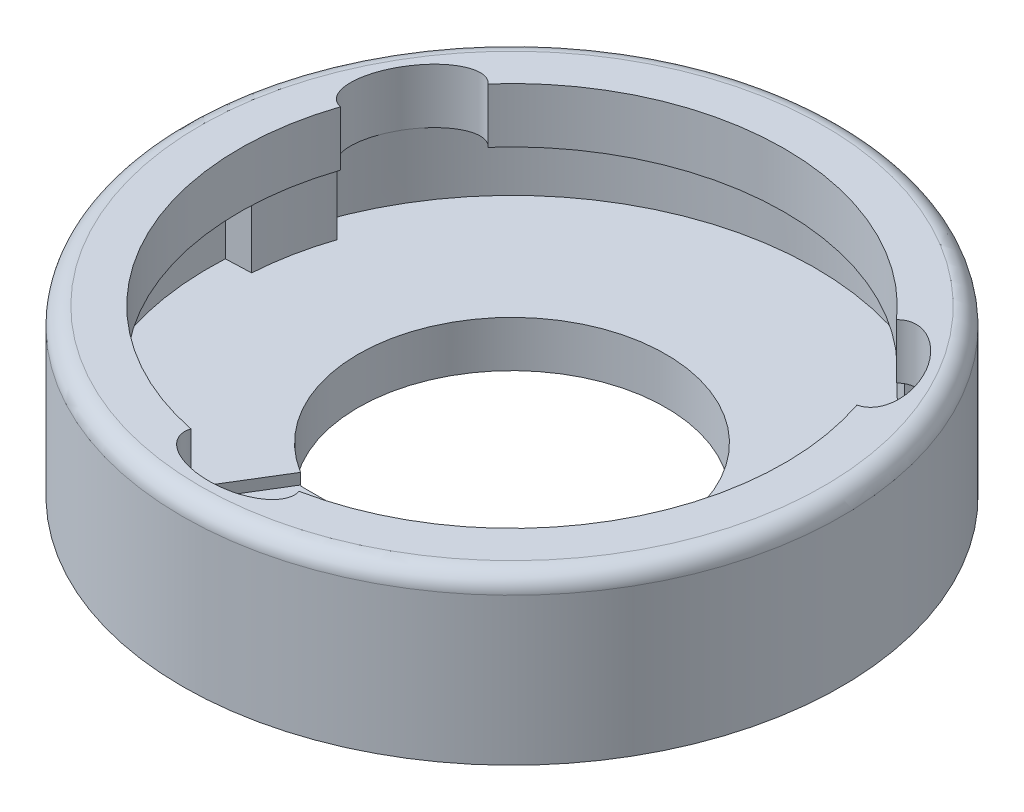
from build123d import *

# Parameters (mm, degrees)
SKIZZE1_R                       = 7.5
SKIZZE1_R_2                     = 3.5
AUFSATZ_LINEAR_AUSTRAGEN2_DEPTH = 0.8
SKIZZE5_R                       = 7.5
SKIZZE5_R_2                     = 6.9
AUFSATZ_LINEAR_AUSTRAGEN4_DEPTH = 1.7
SKIZZE18_R                      = 7.5
SKIZZE18_R_2                    = 6.2
AUFSATZ_LINEAR_AUSTRAGEN5_DEPTH = 1.25
SKIZZE19_RX                     = 1.25
SKIZZE19_RY                     = 0.7
SCHNITT_LINEAR_AUSTRAGEN1_DEPTH = 1.75
AUFSATZ_LINEAR_AUSTRAGEN6_DEPTH = 1.7
AUFSATZ_LINEAR_AUSTRAGEN7_DEPTH = 0.25
KREISMUSTER2_COUNT              = 3
KREISMUSTER4_COUNT              = 3
VERRUNDUNG1_R                   = 0.4
SKIZZE25_W                      = 3.608230109
SKIZZE25_H                      = 2.129095576
AUFSATZ_LINEAR_AUSTRAGEN8_DEPTH = 0.8


with BuildPart() as part:
    # Skizze1 → Aufsatz-Linear austragen2 (new body)
    with BuildSketch(Plane(origin=(0, 0, 0), x_dir=(1, 0, 0), z_dir=(0, 1, 0))):
        Circle(SKIZZE1_R)
        Circle(SKIZZE1_R_2, mode=Mode.SUBTRACT)
    extrude(amount=AUFSATZ_LINEAR_AUSTRAGEN2_DEPTH)

    # Skizze5 → Aufsatz-Linear austragen4 (add)
    with BuildSketch(Plane(origin=(0, 0.8, 0), x_dir=(1, 0, 0), z_dir=(0, 1, 0))):
        Circle(SKIZZE5_R)
        Circle(SKIZZE5_R_2, mode=Mode.SUBTRACT)
    extrude(amount=AUFSATZ_LINEAR_AUSTRAGEN4_DEPTH)

    # Skizze18 → Aufsatz-Linear austragen5 (add)
    with BuildSketch(Plane(origin=(0, 2.5, 0), x_dir=(1, 0, 0), z_dir=(0, 1, 0))):
        Circle(SKIZZE18_R)
        Circle(SKIZZE18_R_2, mode=Mode.SUBTRACT)
    extrude(amount=AUFSATZ_LINEAR_AUSTRAGEN5_DEPTH)

    # Skizze19 → Schnitt-Linear austragen1 (cut)
    with BuildSketch(Plane(origin=(0, 3.75, 0), x_dir=(1, 0, 0), z_dir=(0, 1, 0))):
        with Locations(Location((0, -6.2), (0, 0, 180))):
            Ellipse(SKIZZE19_RX, SKIZZE19_RY)
    schnitt_linear_austragen1 = extrude(amount=-SCHNITT_LINEAR_AUSTRAGEN1_DEPTH, mode=Mode.SUBTRACT)

    # Skizze21 → Aufsatz-Linear austragen6 (add)
    with BuildSketch(Plane(origin=(0, 0.8, 0), x_dir=(1, 0, 0), z_dir=(0, 1, 0))):
        with BuildLine():
            Line((1.25, -6.2), (1.58338324, -7.330954748))
            ThreePointArc((1.58338324, -7.330954748), (2.538105919, -7.057479603), (3.448325605, -6.660259043))
            Line((3.448325605, -6.660259043), (2.820309034, -5.661126827))
            ThreePointArc((2.820309034, -5.661126827), (2.052912561, -5.982311428), (1.25, -6.2))
        make_face()
    aufsatz_linear_austragen6 = extrude(amount=AUFSATZ_LINEAR_AUSTRAGEN6_DEPTH)

    # Skizze22 → Aufsatz-Linear austragen7 (add)
    with BuildSketch(Plane(origin=(0, 0.8, 0), x_dir=(1, 0, 0), z_dir=(0, 1, 0))):
        with BuildLine():
            Line((1.826721278, -2.985479756), (3.601250519, -5.88566009))
            ThreePointArc((3.601250519, -5.88566009), (0, 6.9), (-3.601250519, -5.88566009))
            Line((-3.601250519, -5.88566009), (-1.826721278, -2.985479756))
            ThreePointArc((-1.826721278, -2.985479756), (0, 3.5), (1.826721278, -2.985479756))
        make_face()
    extrude(amount=AUFSATZ_LINEAR_AUSTRAGEN7_DEPTH)

    # Kreismuster2: Schnitt-Linear austragen1 ×3 about axis
    kreismuster2_axis = Axis((0, 3.75, 0), (0, -1, 0))
    for i in range(1, KREISMUSTER2_COUNT):
        add(schnitt_linear_austragen1.rotate(kreismuster2_axis, i * 360 / KREISMUSTER2_COUNT), mode=Mode.SUBTRACT)

    # Kreismuster4: Aufsatz-Linear austragen6 ×3 about axis
    kreismuster4_axis = Axis((0, 0, 0), (0, 1, 0))
    for i in range(1, KREISMUSTER4_COUNT):
        add(aufsatz_linear_austragen6.rotate(kreismuster4_axis, i * 360 / KREISMUSTER4_COUNT))

    # Verrundung1
    verrundung1_edges = [part.edges().sort_by_distance(p)[0] for p in [
        (-7.5, 3.75, 0),
    ]]
    fillet(verrundung1_edges, radius=VERRUNDUNG1_R)

    # Skizze25 → Aufsatz-Linear austragen8 (add)
    with BuildSketch(Plane.XZ):
        with Locations((0.008172181, 4.068643191)):
            Rectangle(SKIZZE25_W, SKIZZE25_H)
    extrude(amount=-AUFSATZ_LINEAR_AUSTRAGEN8_DEPTH)


solid = part.part
